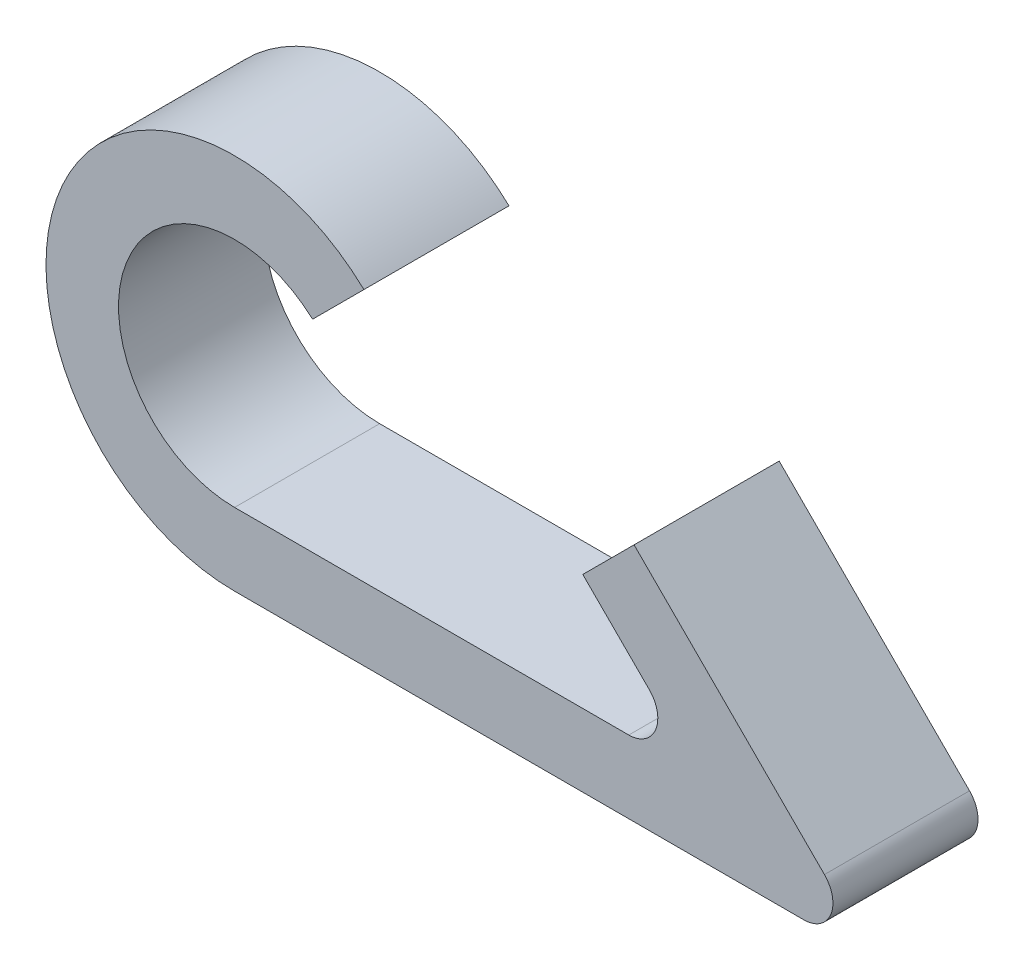
from build123d import *

# Parameters (mm, degrees)
RESSALTO_EXTRUS_O1_DEPTH = 5


with BuildPart() as part:
    # Esboço1 → Ressalto-extrusão1 (new body)
    with BuildSketch(Plane.XY):
        with BuildLine():
            Line((0, -6.5), (19.621320344, -6.5))
            ThreePointArc((19.621320344, -6.5), (20.545199876, -5.882683432), (20.328427125, -4.792893219))
            Line((20.328427125, -4.792893219), (13.767766953, 1.767766953))
            Line((13.767766953, 1.767766953), (12, 0))
            Line((12, 0), (14.292893219, -2.292893219))
            ThreePointArc((14.292893219, -2.292893219), (14.50966597, -3.382683432), (13.585786438, -4))
            Line((13.585786438, -4), (0, -4))
            ThreePointArc((0, -4), (-3.731407445, 1.441040764), (2.688555117, 2.961700759))
            Line((2.688555117, 2.961700759), (4.457591724, 4.730737366))
            ThreePointArc((4.457591724, 4.730737366), (-6.041514416, 2.397937356), (0, -6.5))
        make_face()
    extrude(amount=RESSALTO_EXTRUS_O1_DEPTH)


solid = part.part
